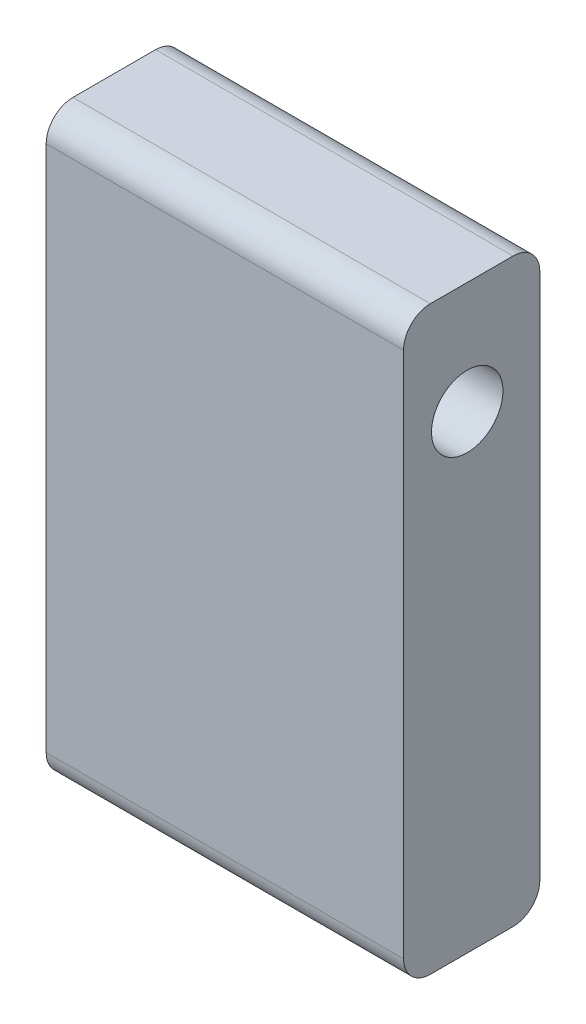
from build123d import *

# Parameters (mm, degrees)
SKETCH1_W           = 6.5
SKETCH1_H           = 26
SKETCH1_R           = 2.8
BOSS_EXTRUDE1_DEPTH = 16
SKETCH1_3_R         = 2.8
SKETCH1_3_R_2       = 1.6
BOSS_EXTRUDE3_DEPTH = 5
CUT_EXTRUDE2_START  = -16
SKETCH1_4_R         = 2.55
CUT_EXTRUDE2_DEPTH  = 8.4
CUT_EXTRUDE1_START  = 3.25
SKETCH2_R           = 50
CUT_EXTRUDE1_DEPTH  = 0.4
FILLET1_R           = 1.2


with BuildPart() as part:
    # Sketch1 → Boss-Extrude1 (new body)
    with BuildSketch(Plane(origin=(0, 0, 0), x_dir=(0, 0, -1), z_dir=(1, 0, 0))):
        with Locations((0, 8)):
            Rectangle(SKETCH1_W, SKETCH1_H)
        with Locations((0, 16)):
            Circle(SKETCH1_R, mode=Mode.SUBTRACT)
    extrude(amount=-BOSS_EXTRUDE1_DEPTH)

    # Sketch1_3 → Boss-Extrude3 (add)
    with BuildSketch(Plane(origin=(0, 0, 0), x_dir=(0, 0, -1), z_dir=(1, 0, 0))):
        with Locations((0, 16)):
            Circle(SKETCH1_3_R)
        with Locations((0, 16)):
            Circle(SKETCH1_3_R_2, mode=Mode.SUBTRACT)
    extrude(amount=-BOSS_EXTRUDE3_DEPTH)

    # Sketch1_4 → Cut-Extrude2 (cut)
    with BuildSketch(Plane(origin=(0, 0, 0), x_dir=(0, 0, -1), z_dir=(1, 0, 0)).offset(CUT_EXTRUDE2_START)):
        with Locations((0, 5)):
            Circle(SKETCH1_4_R)
    extrude(amount=CUT_EXTRUDE2_DEPTH, mode=Mode.SUBTRACT)

    # Sketch2 → Cut-Extrude1 (cut)
    with BuildSketch(Plane.XY.offset(CUT_EXTRUDE1_START)):
        Circle(SKETCH2_R)
    extrude(amount=-CUT_EXTRUDE1_DEPTH, mode=Mode.SUBTRACT)

    # Fillet1
    fillet1_edges = [part.edges().sort_by_distance(p)[0] for p in [
        (-8, 21, -3.25),
        (-8, -5, -3.25),
        (-8, 21, 2.85),
        (-8, -5, 2.85),
    ]]
    fillet(fillet1_edges, radius=FILLET1_R)


solid = part.part
